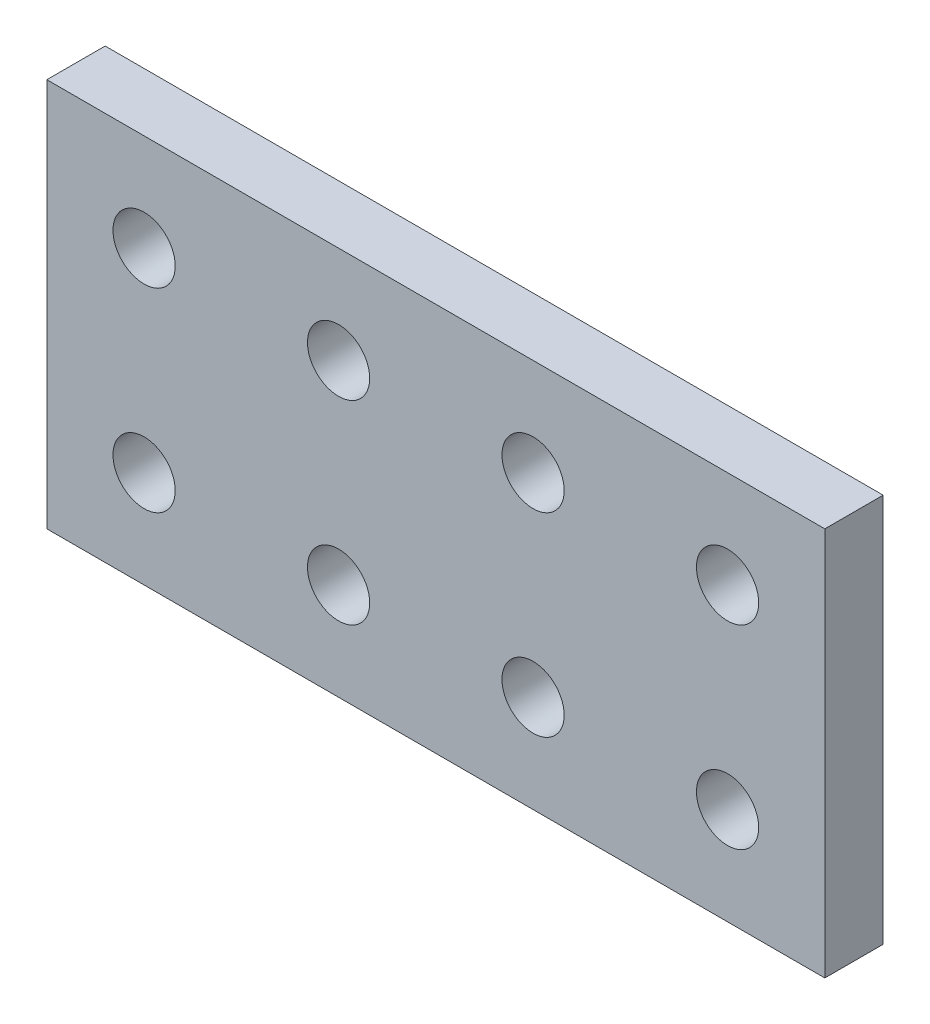
from build123d import *

# Parameters (mm, degrees)
SKETCH_1_W      = 40
SKETCH_1_H      = 20
SKETCH_1_R      = 1.6
EXTRUDE_1_DEPTH = 3


with BuildPart() as part:
    # 草图1 → 凸台-拉伸1 (new body)
    with BuildSketch(Plane.XY):
        with Locations((43.148787463, 17.926985495)):
            Rectangle(SKETCH_1_W, SKETCH_1_H)
        with Locations((48.148787463, 22.926985495)):
            Circle(SKETCH_1_R, mode=Mode.SUBTRACT)
        with Locations((58.148787463, 22.926985495)):
            Circle(SKETCH_1_R, mode=Mode.SUBTRACT)
        with Locations((38.148787463, 22.926985495)):
            Circle(SKETCH_1_R, mode=Mode.SUBTRACT)
        with Locations((28.148787463, 22.926985495)):
            Circle(SKETCH_1_R, mode=Mode.SUBTRACT)
        with Locations((28.148787463, 12.926985495)):
            Circle(SKETCH_1_R, mode=Mode.SUBTRACT)
        with Locations((38.148787463, 12.926985495)):
            Circle(SKETCH_1_R, mode=Mode.SUBTRACT)
        with Locations((48.148787463, 12.926985495)):
            Circle(SKETCH_1_R, mode=Mode.SUBTRACT)
        with Locations((58.148787463, 12.926985495)):
            Circle(SKETCH_1_R, mode=Mode.SUBTRACT)
    extrude(amount=EXTRUDE_1_DEPTH)


solid = part.part
